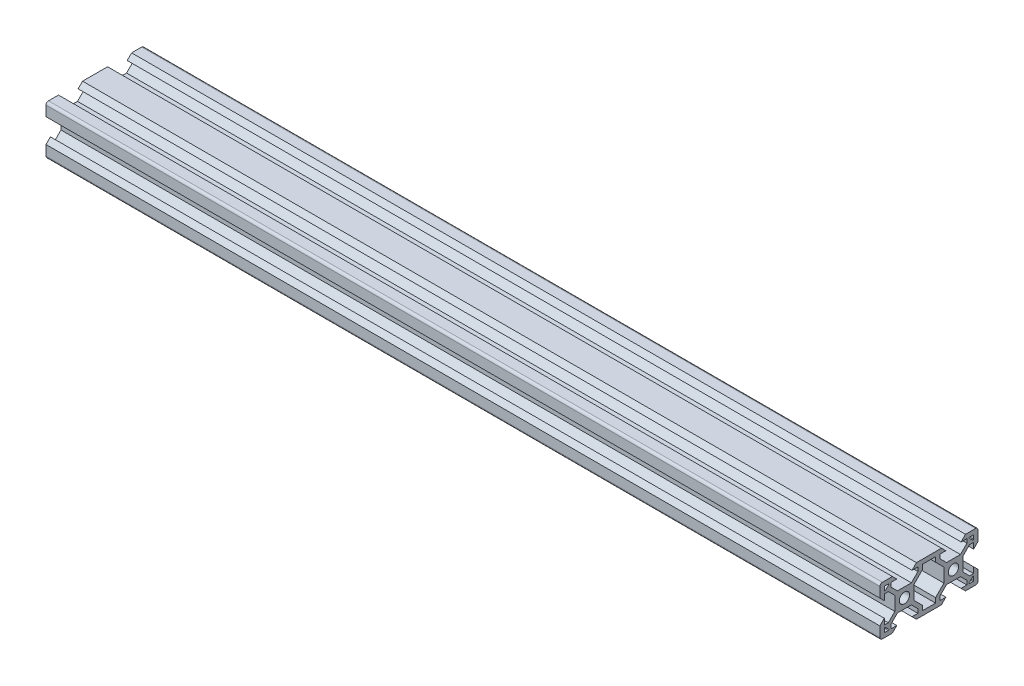
from build123d import *

# Parameters (mm, degrees)
SKETCH5_R           = 2.1
BOSS_EXTRUDE1_DEPTH = 170


with BuildPart() as part:
    # Sketch5 → Boss-Extrude1 (new body, symmetric)
    with BuildSketch(Plane(origin=(0, 0, 0), x_dir=(0, 0, -1), z_dir=(1, 0, 0))):
        with BuildLine():
            Line((-19.998019485, 4.9), (-18.198019485, 3.1))
            Line((-18.198019485, 3.1), (-18.198019485, 5.499339828))
            Line((-18.198019485, 5.499339828), (-16.558019485, 5.499339828))
            Line((-16.558019485, 5.499339828), (-13.9, 2.841320344))
            Line((-13.9, 2.841320344), (-13.9, -2.838679656))
            Line((-13.9, -2.838679656), (-16.558019485, -5.496699141))
            Line((-16.558019485, -5.496699141), (-18.198019485, -5.496699141))
            Line((-18.198019485, -5.496699141), (-18.198019485, -3.1))
            Line((-18.198019485, -3.1), (-19.998019485, -4.9))
            Line((-19.998019485, -4.9), (-19.998019485, -9))
            ThreePointArc((-19.998019485, -9), (-19.705126266, -9.707106781), (-18.998019485, -10))
            Line((-18.998019485, -10), (-14.9, -10))
            Line((-14.9, -10), (-13.1, -8.2))
            Line((-13.1, -8.2), (-15.5, -8.2))
            Line((-15.5, -8.2), (-15.5, -6.56))
            Line((-15.5, -6.56), (-12.84, -3.9))
            Line((-12.84, -3.9), (-7.16, -3.9))
            Line((-7.16, -3.9), (-4.5, -6.56))
            Line((-4.5, -6.56), (-4.5, -8.2))
            Line((-4.5, -8.2), (-6.9, -8.2))
            Line((-6.9, -8.2), (-5.1, -10))
            Line((-5.1, -10), (5.1, -10))
            Line((5.1, -10), (6.9, -8.2))
            Line((6.9, -8.2), (4.496038969, -8.2))
            Line((4.496038969, -8.2), (4.496038969, -6.56))
            Line((4.496038969, -6.56), (7.156038969, -3.9))
            Line((7.156038969, -3.9), (12.836038969, -3.9))
            Line((12.836038969, -3.9), (15.496038969, -6.56))
            Line((15.496038969, -6.56), (15.496038969, -8.2))
            Line((15.496038969, -8.2), (13.1, -8.2))
            Line((13.1, -8.2), (14.9, -10))
            Line((14.9, -10), (19.001980515, -10))
            ThreePointArc((19.001980515, -10), (19.709087297, -9.707106781), (20.001980515, -9))
            Line((20.001980515, -9), (20.001980515, -4.9))
            Line((20.001980515, -4.9), (18.201980515, -3.1))
            Line((18.201980515, -3.1), (18.201980515, -5.504621202))
            Line((18.201980515, -5.504621202), (16.561980515, -5.504621202))
            Line((16.561980515, -5.504621202), (13.9, -2.842640687))
            Line((13.9, -2.842640687), (13.9, 2.837359313))
            Line((13.9, 2.837359313), (16.561980515, 5.499339828))
            Line((16.561980515, 5.499339828), (18.201980515, 5.499339828))
            Line((18.201980515, 5.499339828), (18.201980515, 3.1))
            Line((18.201980515, 3.1), (20.001980515, 4.9))
            Line((20.001980515, 4.9), (20.001980515, 9))
            ThreePointArc((20.001980515, 9), (19.709087297, 9.707106781), (19.001980515, 10))
            Line((19.001980515, 10), (14.9, 10))
            Line((14.9, 10), (13.1, 8.2))
            Line((13.1, 8.2), (15.501320344, 8.2))
            Line((15.501320344, 8.2), (15.501320344, 6.56))
            Line((15.501320344, 6.56), (12.841320344, 3.9))
            Line((12.841320344, 3.9), (7.161320344, 3.9))
            Line((7.161320344, 3.9), (4.501320344, 6.56))
            Line((4.501320344, 6.56), (4.501320344, 8.2))
            Line((4.501320344, 8.2), (6.9, 8.2))
            Line((6.9, 8.2), (5.1, 10))
            Line((5.1, 10), (-5.1, 10))
            Line((-5.1, 10), (-6.9, 8.2))
            Line((-6.9, 8.2), (-4.501320344, 8.2))
            Line((-4.501320344, 8.2), (-4.501320344, 6.56))
            Line((-4.501320344, 6.56), (-7.161320344, 3.9))
            Line((-7.161320344, 3.9), (-12.841320344, 3.9))
            Line((-12.841320344, 3.9), (-15.501320344, 6.56))
            Line((-15.501320344, 6.56), (-15.501320344, 8.2))
            Line((-15.501320344, 8.2), (-13.1, 8.2))
            Line((-13.1, 8.2), (-14.9, 10))
            Line((-14.9, 10), (-18.998019485, 10))
            ThreePointArc((-18.998019485, 10), (-19.705126266, 9.707106781), (-19.998019485, 9))
            Line((-19.998019485, 9), (-19.998019485, 4.9))
        make_face()
        with Locations((-10, 0)):
            Circle(SKETCH5_R, mode=Mode.SUBTRACT)
        with Locations((10, 0)):
            Circle(SKETCH5_R, mode=Mode.SUBTRACT)
        Polygon((6.1, -2.84), (6.1, 2.84), (2.7, 6.24), (2.7, 8.2), (-2.7, 8.2), (-2.7, 6.24), (-6.1, 2.84), (-6.1, -2.84), (-2.7, -6.24), (-2.7, -8.2), (2.7, -8.2), (2.7, -6.24), align=None, mode=Mode.SUBTRACT)
        with BuildLine():
            Line((16.571320344, 8.2), (18.001980515, 8.2))
            ThreePointArc((18.001980515, 8.2), (18.143401872, 8.141421356), (18.201980515, 8))
            Line((18.201980515, 8), (18.201980515, 6.569339828))
            ThreePointArc((18.201980515, 6.569339828), (18.078517202, 6.384563922), (17.860559159, 6.427918472))
            Line((17.860559159, 6.427918472), (16.429898987, 7.858578644))
            ThreePointArc((16.429898987, 7.858578644), (16.386544437, 8.076536686), (16.571320344, 8.2))
        make_face(mode=Mode.SUBTRACT)
        with BuildLine():
            Line((16.571320344, -8.2), (18.001980515, -8.2))
            ThreePointArc((18.001980515, -8.2), (18.143401872, -8.141421356), (18.201980515, -8))
            Line((18.201980515, -8), (18.201980515, -6.569339828))
            ThreePointArc((18.201980515, -6.569339828), (18.078517202, -6.384563922), (17.860559159, -6.427918472))
            Line((17.860559159, -6.427918472), (16.429898987, -7.858578644))
            ThreePointArc((16.429898987, -7.858578644), (16.386544437, -8.076536686), (16.571320344, -8.2))
        make_face(mode=Mode.SUBTRACT)
        with BuildLine():
            Line((-17.860559159, 6.427918472), (-16.429898987, 7.858578644))
            ThreePointArc((-16.429898987, 7.858578644), (-16.386544437, 8.076536686), (-16.571320344, 8.2))
            Line((-16.571320344, 8.2), (-18.001980515, 8.2))
            ThreePointArc((-18.001980515, 8.2), (-18.143401872, 8.141421356), (-18.201980515, 8))
            Line((-18.201980515, 8), (-18.201980515, 6.569339828))
            ThreePointArc((-18.201980515, 6.569339828), (-18.078517202, 6.384563922), (-17.860559159, 6.427918472))
        make_face(mode=Mode.SUBTRACT)
        with BuildLine():
            Line((-16.571320344, -8.2), (-18.001980515, -8.2))
            ThreePointArc((-18.001980515, -8.2), (-18.143401872, -8.141421356), (-18.201980515, -8))
            Line((-18.201980515, -8), (-18.201980515, -6.569339828))
            ThreePointArc((-18.201980515, -6.569339828), (-18.078517202, -6.384563922), (-17.860559159, -6.427918472))
            Line((-17.860559159, -6.427918472), (-16.429898987, -7.858578644))
            ThreePointArc((-16.429898987, -7.858578644), (-16.386544437, -8.076536686), (-16.571320344, -8.2))
        make_face(mode=Mode.SUBTRACT)
    extrude(amount=BOSS_EXTRUDE1_DEPTH, both=True)


solid = part.part
